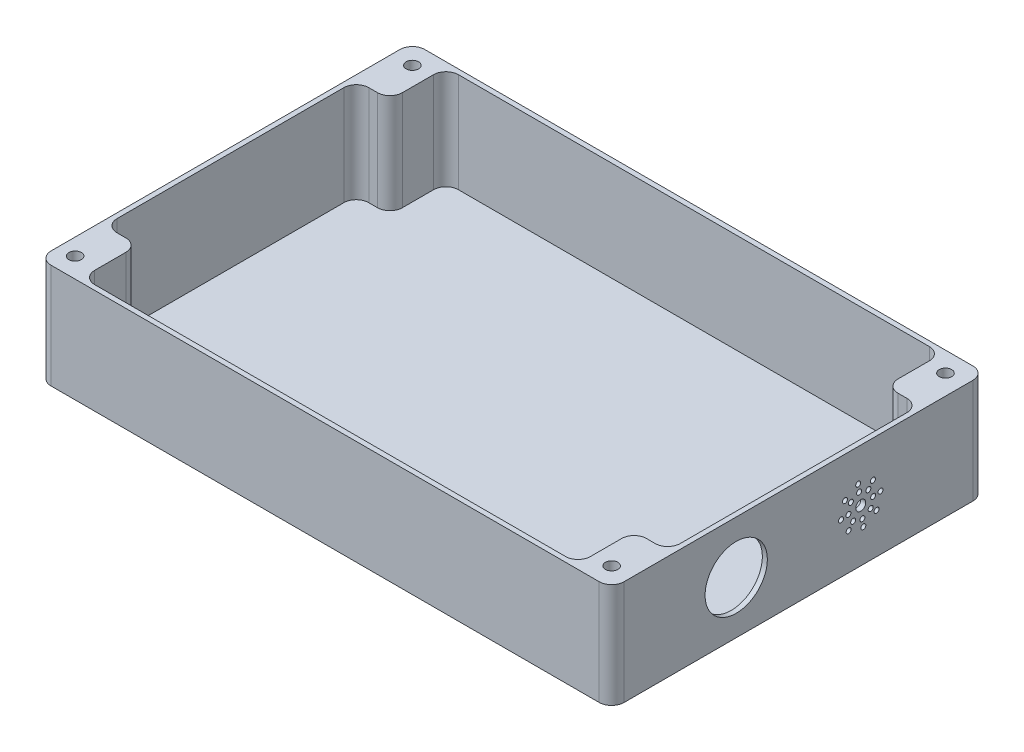
from build123d import *

# Parameters (mm, degrees)
SKETCH_1_W          = 230
SKETCH_1_H          = 150
EXTRUDE_1_DEPTH     = 42
CUT_EXTRUDE_2_DEPTH = 40
FILLET_1_R          = 5
FILLET_2_R          = 5
SKETCH_5_R          = 2.5
CUT_EXTRUDE_3_DEPTH = 43
SKETCH_6_R          = 12.5
CUT_EXTRUDE_4_DEPTH = 10
CUT_EXTRUDE_5_REACH = 232
SKETCH_9_R          = 2
SKETCH_9_R_2        = 1


with BuildPart() as part:
    # 草图1 → 凸台-拉伸1 (new body)
    with BuildSketch(Plane(origin=(0, 0, 0), x_dir=(1, 0, 0), z_dir=(0, 1, 0))):
        with Locations((115, 75)):
            Rectangle(SKETCH_1_W, SKETCH_1_H)
    extrude(amount=EXTRUDE_1_DEPTH)

    # 草图4 → 切除-拉伸2 (cut)
    with BuildSketch(Plane(origin=(0, 42, 0), x_dir=(1, 0, 0), z_dir=(0, 1, 0))):
        Polygon((2, 125.5), (2, 24.5), (15.5, 24.5), (15.5, 2), (214.5, 2), (214.5, 24.5), (228, 24.5), (228, 125.5), (214.5, 125.5), (214.5, 148), (15.5, 148), (15.5, 125.5), align=None)
    extrude(amount=-CUT_EXTRUDE_2_DEPTH, mode=Mode.SUBTRACT)

    # 圆角1
    fillet_1_edges = [part.edges().sort_by_distance(p)[0] for p in [
        (0, 21, -150),
        (0, 21, 0),
        (230, 21, 0),
        (230, 21, -150),
    ]]
    fillet(fillet_1_edges, radius=FILLET_1_R)

    # 圆角2
    fillet_2_edges = [part.edges().sort_by_distance(p)[0] for p in [
        (2, 22, -125.5),
        (15.5, 22, -125.5),
        (15.5, 22, -148),
        (214.5, 22, -148),
        (214.5, 22, -125.5),
        (228, 22, -125.5),
        (228, 22, -24.5),
        (214.5, 22, -24.5),
        (214.5, 22, -2),
        (15.5, 22, -2),
        (15.5, 22, -24.5),
        (2, 22, -24.5),
    ]]
    fillet(fillet_2_edges, radius=FILLET_2_R)

    # 草图5 → 切除-拉伸3 (cut, through all)
    with BuildSketch(Plane(origin=(0, 42, 0), x_dir=(1, 0, 0), z_dir=(0, 1, 0))):
        with Locations((222, 142)):
            Circle(SKETCH_5_R)
        with Locations((6.63178387, 8)):
            Circle(SKETCH_5_R)
        with Locations((222, 8)):
            Circle(SKETCH_5_R)
        with Locations((8, 142)):
            Circle(SKETCH_5_R)
    extrude(amount=-CUT_EXTRUDE_3_DEPTH, mode=Mode.SUBTRACT)

    # 草图6 → 切除-拉伸4 (cut)
    with BuildSketch(Plane(origin=(230, 0, 0), x_dir=(0, 0, -1), z_dir=(1, 0, 0))):
        with Locations((50, 21)):
            Circle(SKETCH_6_R)
    extrude(amount=-CUT_EXTRUDE_4_DEPTH, mode=Mode.SUBTRACT)

    # 草图9 → 切除-拉伸5 (cut, up to next)
    with BuildSketch(Plane(origin=(230, 0, 0), x_dir=(0, 0, -1), z_dir=(1, 0, 0)), mode=Mode.PRIVATE) as cut_extrude_5_sk1:
        with Locations((100, 21)):
            Circle(SKETCH_9_R)
    cut_extrude_5_tool1 = extrude(cut_extrude_5_sk1.sketch, amount=-CUT_EXTRUDE_5_REACH, mode=Mode.PRIVATE) & part.part
    add(cut_extrude_5_tool1.solids().sort_by_distance((230, 21, -100))[0], mode=Mode.SUBTRACT)
    # 草图9 → 切除-拉伸5 (cut, up to next)
    with BuildSketch(Plane(origin=(230, 0, 0), x_dir=(0, 0, -1), z_dir=(1, 0, 0)), mode=Mode.PRIVATE) as cut_extrude_5_sk2:
        with Locations((103.04364251, 24.966893025)):
            Circle(SKETCH_9_R_2)
    cut_extrude_5_tool2 = extrude(cut_extrude_5_sk2.sketch, amount=-CUT_EXTRUDE_5_REACH, mode=Mode.PRIVATE) & part.part
    add(cut_extrude_5_tool2.solids().sort_by_distance((230, 24.966893, -103.043643))[0], mode=Mode.SUBTRACT)
    # 草图9 → 切除-拉伸5 (cut, up to next)
    with BuildSketch(Plane(origin=(230, 0, 0), x_dir=(0, 0, -1), z_dir=(1, 0, 0)), mode=Mode.PRIVATE) as cut_extrude_5_sk3:
        with Locations((104.869828016, 27.34702884)):
            Circle(SKETCH_9_R_2)
    cut_extrude_5_tool3 = extrude(cut_extrude_5_sk3.sketch, amount=-CUT_EXTRUDE_5_REACH, mode=Mode.PRIVATE) & part.part
    add(cut_extrude_5_tool3.solids().sort_by_distance((230, 27.347029, -104.869828))[0], mode=Mode.SUBTRACT)
    # 草图9 → 切除-拉伸5 (cut, up to next)
    with BuildSketch(Plane(origin=(230, 0, 0), x_dir=(0, 0, -1), z_dir=(1, 0, 0)), mode=Mode.PRIVATE) as cut_extrude_5_sk4:
        with Locations((104.957197217, 21.6528367)):
            Circle(SKETCH_9_R_2)
    cut_extrude_5_tool4 = extrude(cut_extrude_5_sk4.sketch, amount=-CUT_EXTRUDE_5_REACH, mode=Mode.PRIVATE) & part.part
    add(cut_extrude_5_tool4.solids().sort_by_distance((230, 21.652837, -104.957197))[0], mode=Mode.SUBTRACT)
    # 草图9 → 切除-拉伸5 (cut, up to next)
    with BuildSketch(Plane(origin=(230, 0, 0), x_dir=(0, 0, -1), z_dir=(1, 0, 0)), mode=Mode.PRIVATE) as cut_extrude_5_sk5:
        with Locations((103.966893025, 17.95635749)):
            Circle(SKETCH_9_R_2)
    cut_extrude_5_tool5 = extrude(cut_extrude_5_sk5.sketch, amount=-CUT_EXTRUDE_5_REACH, mode=Mode.PRIVATE) & part.part
    add(cut_extrude_5_tool5.solids().sort_by_distance((230, 17.956357, -103.966893))[0], mode=Mode.SUBTRACT)
    # 草图9 → 切除-拉伸5 (cut, up to next)
    with BuildSketch(Plane(origin=(230, 0, 0), x_dir=(0, 0, -1), z_dir=(1, 0, 0)), mode=Mode.PRIVATE) as cut_extrude_5_sk6:
        with Locations((100.6528367, 16.042802783)):
            Circle(SKETCH_9_R_2)
    cut_extrude_5_tool6 = extrude(cut_extrude_5_sk6.sketch, amount=-CUT_EXTRUDE_5_REACH, mode=Mode.PRIVATE) & part.part
    add(cut_extrude_5_tool6.solids().sort_by_distance((230, 16.042803, -100.652837))[0], mode=Mode.SUBTRACT)
    # 草图9 → 切除-拉伸5 (cut, up to next)
    with BuildSketch(Plane(origin=(230, 0, 0), x_dir=(0, 0, -1), z_dir=(1, 0, 0)), mode=Mode.PRIVATE) as cut_extrude_5_sk7:
        with Locations((96.95635749, 17.033106975)):
            Circle(SKETCH_9_R_2)
    cut_extrude_5_tool7 = extrude(cut_extrude_5_sk7.sketch, amount=-CUT_EXTRUDE_5_REACH, mode=Mode.PRIVATE) & part.part
    add(cut_extrude_5_tool7.solids().sort_by_distance((230, 17.033107, -96.956357))[0], mode=Mode.SUBTRACT)
    # 草图9 → 切除-拉伸5 (cut, up to next)
    with BuildSketch(Plane(origin=(230, 0, 0), x_dir=(0, 0, -1), z_dir=(1, 0, 0)), mode=Mode.PRIVATE) as cut_extrude_5_sk8:
        with Locations((95.042802783, 20.3471633)):
            Circle(SKETCH_9_R_2)
    cut_extrude_5_tool8 = extrude(cut_extrude_5_sk8.sketch, amount=-CUT_EXTRUDE_5_REACH, mode=Mode.PRIVATE) & part.part
    add(cut_extrude_5_tool8.solids().sort_by_distance((230, 20.347163, -95.042803))[0], mode=Mode.SUBTRACT)
    # 草图9 → 切除-拉伸5 (cut, up to next)
    with BuildSketch(Plane(origin=(230, 0, 0), x_dir=(0, 0, -1), z_dir=(1, 0, 0)), mode=Mode.PRIVATE) as cut_extrude_5_sk9:
        with Locations((96.033106975, 24.04364251)):
            Circle(SKETCH_9_R_2)
    cut_extrude_5_tool9 = extrude(cut_extrude_5_sk9.sketch, amount=-CUT_EXTRUDE_5_REACH, mode=Mode.PRIVATE) & part.part
    add(cut_extrude_5_tool9.solids().sort_by_distance((230, 24.043643, -96.033107))[0], mode=Mode.SUBTRACT)
    # 草图9 → 切除-拉伸5 (cut, up to next)
    with BuildSketch(Plane(origin=(230, 0, 0), x_dir=(0, 0, -1), z_dir=(1, 0, 0)), mode=Mode.PRIVATE) as cut_extrude_5_sk10:
        with Locations((99.3471633, 25.957197217)):
            Circle(SKETCH_9_R_2)
    cut_extrude_5_tool10 = extrude(cut_extrude_5_sk10.sketch, amount=-CUT_EXTRUDE_5_REACH, mode=Mode.PRIVATE) & part.part
    add(cut_extrude_5_tool10.solids().sort_by_distance((230, 25.957197, -99.347163))[0], mode=Mode.SUBTRACT)
    # 草图9 → 切除-拉伸5 (cut, up to next)
    with BuildSketch(Plane(origin=(230, 0, 0), x_dir=(0, 0, -1), z_dir=(1, 0, 0)), mode=Mode.PRIVATE) as cut_extrude_5_sk11:
        with Locations((107.931515546, 22.04453872)):
            Circle(SKETCH_9_R_2)
    cut_extrude_5_tool11 = extrude(cut_extrude_5_sk11.sketch, amount=-CUT_EXTRUDE_5_REACH, mode=Mode.PRIVATE) & part.part
    add(cut_extrude_5_tool11.solids().sort_by_distance((230, 22.044539, -107.931516))[0], mode=Mode.SUBTRACT)
    # 草图9 → 切除-拉伸5 (cut, up to next)
    with BuildSketch(Plane(origin=(230, 0, 0), x_dir=(0, 0, -1), z_dir=(1, 0, 0)), mode=Mode.PRIVATE) as cut_extrude_5_sk12:
        with Locations((106.34702884, 16.130171984)):
            Circle(SKETCH_9_R_2)
    cut_extrude_5_tool12 = extrude(cut_extrude_5_sk12.sketch, amount=-CUT_EXTRUDE_5_REACH, mode=Mode.PRIVATE) & part.part
    add(cut_extrude_5_tool12.solids().sort_by_distance((230, 16.130172, -106.347029))[0], mode=Mode.SUBTRACT)
    # 草图9 → 切除-拉伸5 (cut, up to next)
    with BuildSketch(Plane(origin=(230, 0, 0), x_dir=(0, 0, -1), z_dir=(1, 0, 0)), mode=Mode.PRIVATE) as cut_extrude_5_sk13:
        with Locations((101.04453872, 13.068484454)):
            Circle(SKETCH_9_R_2)
    cut_extrude_5_tool13 = extrude(cut_extrude_5_sk13.sketch, amount=-CUT_EXTRUDE_5_REACH, mode=Mode.PRIVATE) & part.part
    add(cut_extrude_5_tool13.solids().sort_by_distance((230, 13.068484, -101.044539))[0], mode=Mode.SUBTRACT)
    # 草图9 → 切除-拉伸5 (cut, up to next)
    with BuildSketch(Plane(origin=(230, 0, 0), x_dir=(0, 0, -1), z_dir=(1, 0, 0)), mode=Mode.PRIVATE) as cut_extrude_5_sk14:
        with Locations((95.130171984, 14.65297116)):
            Circle(SKETCH_9_R_2)
    cut_extrude_5_tool14 = extrude(cut_extrude_5_sk14.sketch, amount=-CUT_EXTRUDE_5_REACH, mode=Mode.PRIVATE) & part.part
    add(cut_extrude_5_tool14.solids().sort_by_distance((230, 14.652971, -95.130172))[0], mode=Mode.SUBTRACT)
    # 草图9 → 切除-拉伸5 (cut, up to next)
    with BuildSketch(Plane(origin=(230, 0, 0), x_dir=(0, 0, -1), z_dir=(1, 0, 0)), mode=Mode.PRIVATE) as cut_extrude_5_sk15:
        with Locations((92.068484454, 19.95546128)):
            Circle(SKETCH_9_R_2)
    cut_extrude_5_tool15 = extrude(cut_extrude_5_sk15.sketch, amount=-CUT_EXTRUDE_5_REACH, mode=Mode.PRIVATE) & part.part
    add(cut_extrude_5_tool15.solids().sort_by_distance((230, 19.955461, -92.068484))[0], mode=Mode.SUBTRACT)
    # 草图9 → 切除-拉伸5 (cut, up to next)
    with BuildSketch(Plane(origin=(230, 0, 0), x_dir=(0, 0, -1), z_dir=(1, 0, 0)), mode=Mode.PRIVATE) as cut_extrude_5_sk16:
        with Locations((93.65297116, 25.869828016)):
            Circle(SKETCH_9_R_2)
    cut_extrude_5_tool16 = extrude(cut_extrude_5_sk16.sketch, amount=-CUT_EXTRUDE_5_REACH, mode=Mode.PRIVATE) & part.part
    add(cut_extrude_5_tool16.solids().sort_by_distance((230, 25.869828, -93.652971))[0], mode=Mode.SUBTRACT)
    # 草图9 → 切除-拉伸5 (cut, up to next)
    with BuildSketch(Plane(origin=(230, 0, 0), x_dir=(0, 0, -1), z_dir=(1, 0, 0)), mode=Mode.PRIVATE) as cut_extrude_5_sk17:
        with Locations((98.95546128, 28.931515546)):
            Circle(SKETCH_9_R_2)
    cut_extrude_5_tool17 = extrude(cut_extrude_5_sk17.sketch, amount=-CUT_EXTRUDE_5_REACH, mode=Mode.PRIVATE) & part.part
    add(cut_extrude_5_tool17.solids().sort_by_distance((230, 28.931516, -98.955461))[0], mode=Mode.SUBTRACT)


solid = part.part
